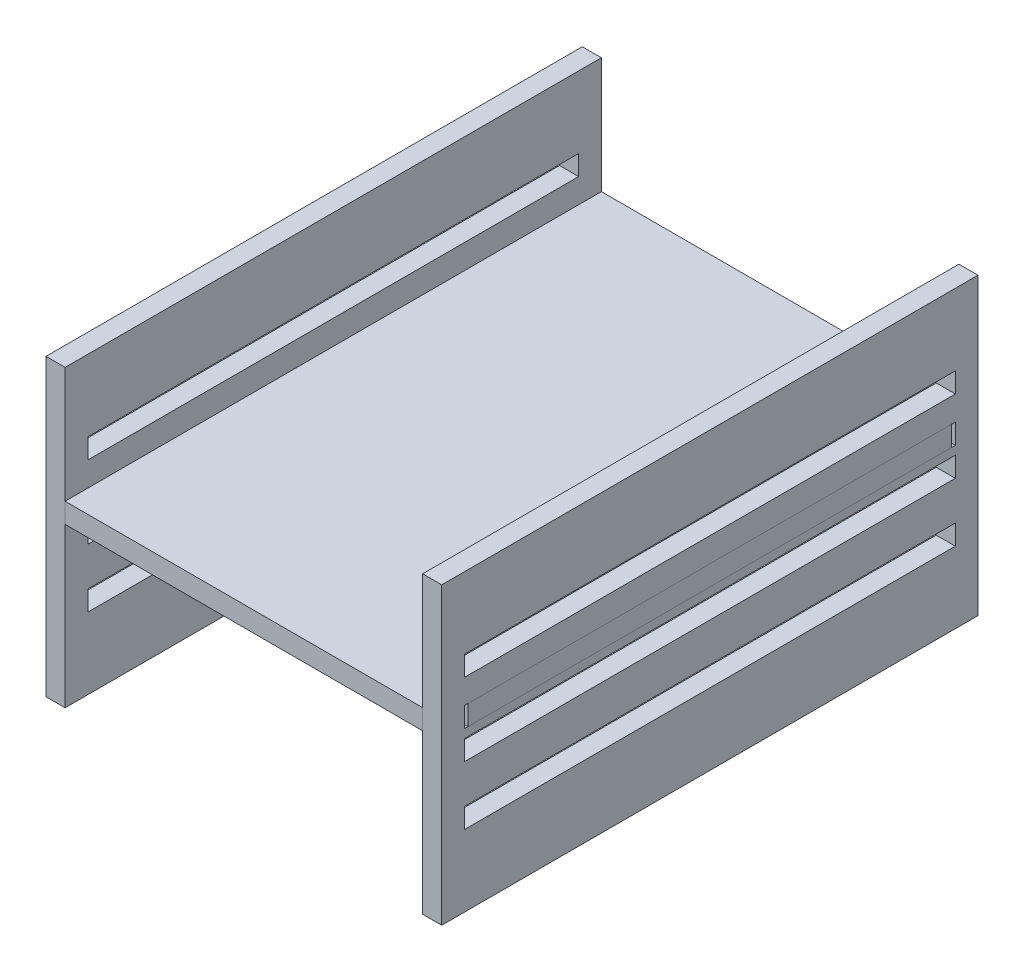
from build123d import *

# Parameters (mm, degrees)
BOSS_EXTRUDE1_START = 25
SKETCH1_W           = 75
SKETCH1_H           = 41.232
SKETCH1_W_2         = 68.65
SKETCH1_H_2         = 2.8
BOSS_EXTRUDE1_DEPTH = 2.67
BOSS_EXTRUDE2_START = -25
SKETCH1_2_W         = 75
SKETCH1_2_H         = 41.232
SKETCH1_2_W_2       = 68.65
SKETCH1_2_H_2       = 2.8
BOSS_EXTRUDE2_DEPTH = 2.67
BOSS_EXTRUDE3_DEPTH = 2.8


with BuildPart() as part:
    # Sketch1 → Boss-Extrude1 (new body)
    with BuildSketch(Plane(origin=(0, 0, 0), x_dir=(0, 0, -1), z_dir=(1, 0, 0)).offset(BOSS_EXTRUDE1_START)):
        Rectangle(SKETCH1_W, SKETCH1_H)
        with Locations((0, -9.216)):
            Rectangle(SKETCH1_W_2, SKETCH1_H_2, mode=Mode.SUBTRACT)
        with Locations((0, -0.996)):
            Rectangle(SKETCH1_W_2, SKETCH1_H_2, mode=Mode.SUBTRACT)
        with Locations((0, 3.004)):
            Rectangle(SKETCH1_W_2, SKETCH1_H_2, mode=Mode.SUBTRACT)
        with Locations((0, 9.216)):
            Rectangle(SKETCH1_W_2, SKETCH1_H_2, mode=Mode.SUBTRACT)
    extrude(amount=BOSS_EXTRUDE1_DEPTH)


with BuildPart() as body_2:
    # Sketch1_2 → Boss-Extrude2 (new body)
    with BuildSketch(Plane(origin=(0, 0, 0), x_dir=(0, 0, -1), z_dir=(1, 0, 0)).offset(BOSS_EXTRUDE2_START)):
        Rectangle(SKETCH1_2_W, SKETCH1_2_H)
        with Locations((0, -9.216)):
            Rectangle(SKETCH1_2_W_2, SKETCH1_2_H_2, mode=Mode.SUBTRACT)
        with Locations((0, -0.996)):
            Rectangle(SKETCH1_2_W_2, SKETCH1_2_H_2, mode=Mode.SUBTRACT)
        with Locations((0, 3.004)):
            Rectangle(SKETCH1_2_W_2, SKETCH1_2_H_2, mode=Mode.SUBTRACT)
        with Locations((0, 9.216)):
            Rectangle(SKETCH1_2_W_2, SKETCH1_2_H_2, mode=Mode.SUBTRACT)
    extrude(amount=-BOSS_EXTRUDE2_DEPTH)


with BuildPart() as body_3:
    # Sketch2 → Boss-Extrude3 (new body)
    with BuildSketch(Plane(origin=(0, 1.604, 0), x_dir=(1, 0, 0), z_dir=(0, 1, 0))):
        Polygon((-27.67, 33.825), (-27.67, -33.825), (-25, -33.825), (-25, -37.5), (25, -37.5), (25, -33.825), (27.67, -33.825), (27.67, 33.825), (25, 33.825), (25, 37.5), (-25, 37.5), (-25, 33.825), align=None)
    extrude(amount=BOSS_EXTRUDE3_DEPTH)


solid = Compound([part.part, body_2.part, body_3.part])
